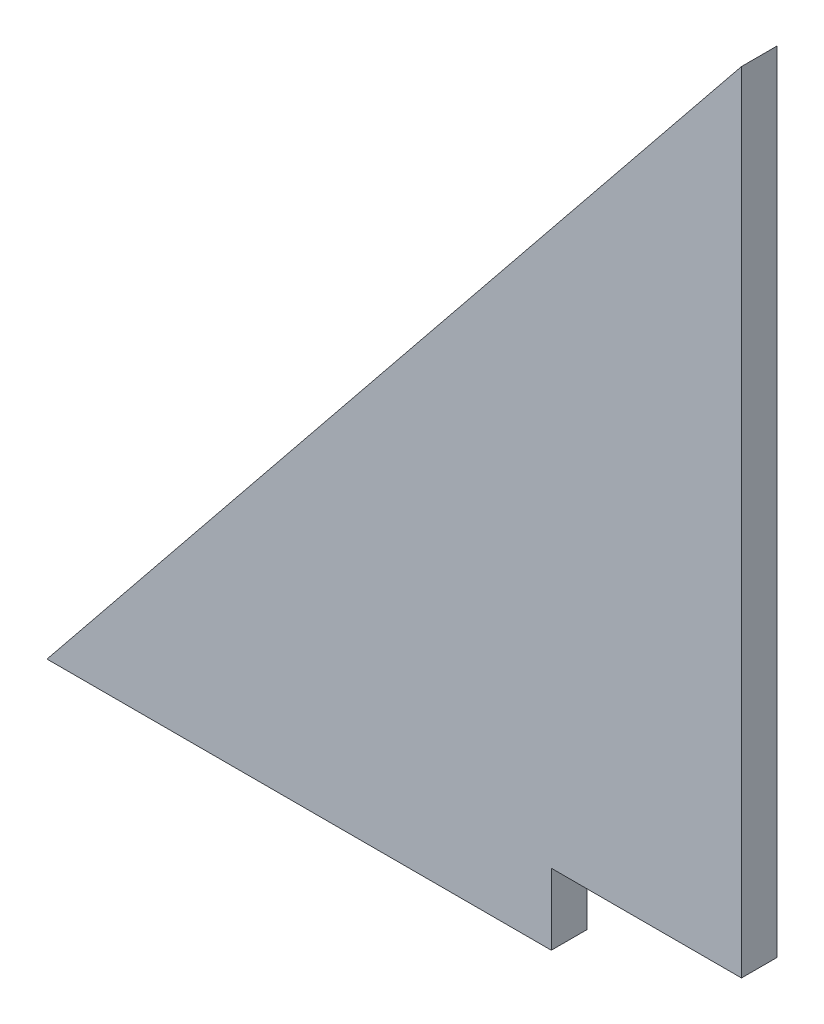
from build123d import *

# Parameters (mm, degrees)
BOSS_EXTRUDE1_DEPTH = 3.175


with BuildPart() as part:
    # Sketch1 → Boss-Extrude1 (new body)
    with BuildSketch(Plane.XY):
        Polygon((-16.826988174, -36.936739334), (-16.921467096, -36.936739334), (-16.921467096, -43.288254706), (-62, -43.288254706), (0.078034456, 33.622826087), (0.078034456, -36.936739334), align=None)
    extrude(amount=BOSS_EXTRUDE1_DEPTH)


solid = part.part
